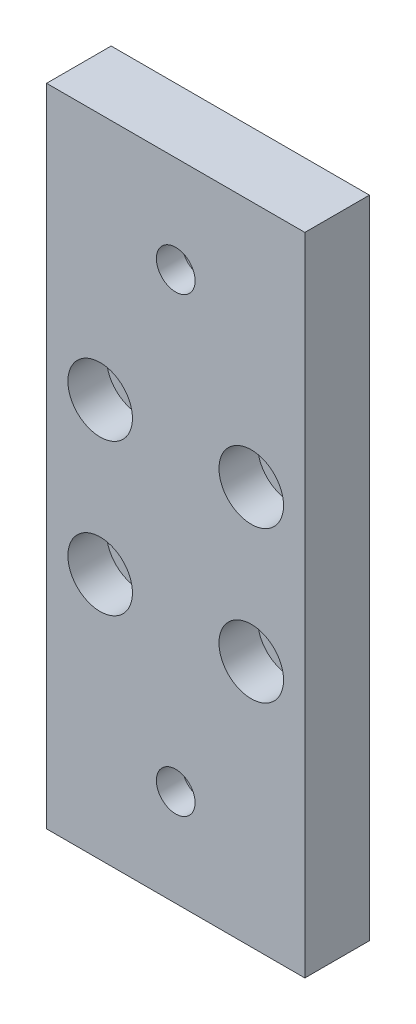
from build123d import *

# Parameters (mm, degrees)
SKETCH1_W           = 40
SKETCH1_H           = 100
BOSS_EXTRUDE1_DEPTH = 10
SKETCH3_R           = 2.5
CUT_EXTRUDE1_DEPTH  = 40
SKETCH4_R           = 5
CUT_EXTRUDE2_DEPTH  = 6
SKETCH6_R           = 5
CUT_EXTRUDE3_DEPTH  = 6
SKETCH7_R           = 3
CUT_EXTRUDE4_DEPTH  = 5


with BuildPart() as part:
    # Sketch1 → Boss-Extrude1 (new body)
    with BuildSketch(Plane.XY):
        with Locations((20, 50)):
            Rectangle(SKETCH1_W, SKETCH1_H)
    extrude(amount=BOSS_EXTRUDE1_DEPTH)

    # Sketch3 → Cut-Extrude1 (cut)
    with BuildSketch(Plane.XY.offset(10)):
        with Locations((8.3, 61.7)):
            Circle(SKETCH3_R)
        with Locations((31.7, 61.7)):
            Circle(SKETCH3_R)
        with Locations((31.7, 38.3)):
            Circle(SKETCH3_R)
        with Locations((8.3, 38.3)):
            Circle(SKETCH3_R)
    extrude(amount=-CUT_EXTRUDE1_DEPTH, mode=Mode.SUBTRACT)

    # Sketch4 → Cut-Extrude2 (cut)
    with BuildSketch(Plane.XY.offset(10)):
        with Locations((8.3, 61.7)):
            Circle(SKETCH4_R)
        with Locations((31.7, 61.7)):
            Circle(SKETCH4_R)
        with Locations((31.7, 38.3)):
            Circle(SKETCH4_R)
        with Locations((8.3, 38.3)):
            Circle(SKETCH4_R)
    extrude(amount=-CUT_EXTRUDE2_DEPTH, mode=Mode.SUBTRACT)

    # Sketch6 → Cut-Extrude3 (cut)
    with BuildSketch(Plane(origin=(0, 0, 0), x_dir=(-1, 0, 0), z_dir=(0, 0, -1))):
        with Locations((-20, 85)):
            Circle(SKETCH6_R)
        with Locations((-20, 15)):
            Circle(SKETCH6_R)
    extrude(amount=-CUT_EXTRUDE3_DEPTH, mode=Mode.SUBTRACT)

    # Sketch7 → Cut-Extrude4 (cut, through all)
    with BuildSketch(Plane(origin=(0, 0, 6), x_dir=(-1, 0, 0), z_dir=(0, 0, -1))):
        with Locations((-20, 15)):
            Circle(SKETCH7_R)
        with Locations((-20, 85)):
            Circle(SKETCH7_R)
    extrude(amount=-CUT_EXTRUDE4_DEPTH, mode=Mode.SUBTRACT)


solid = part.part
